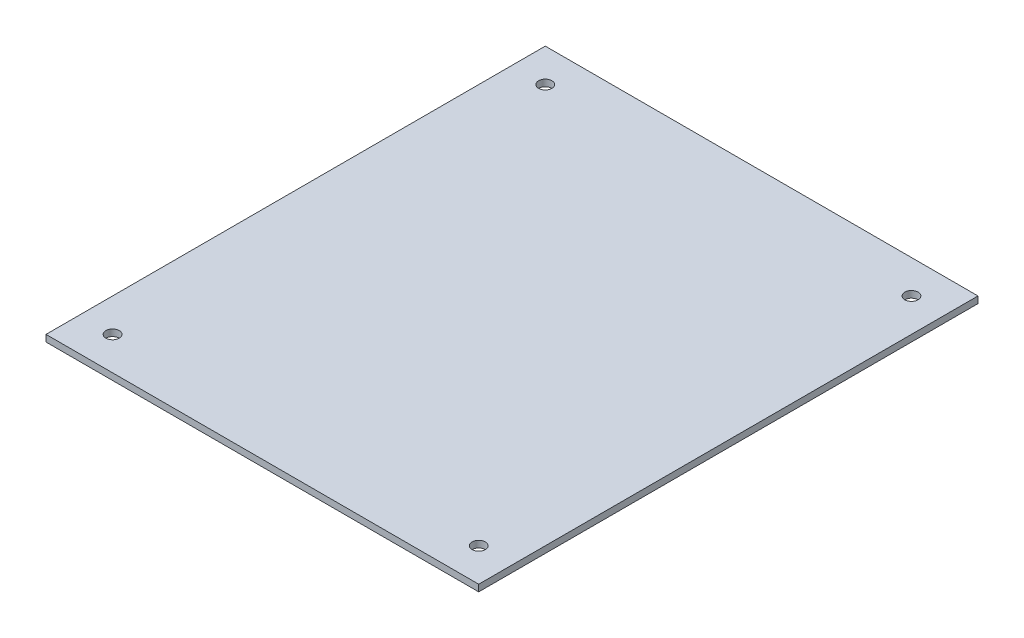
from build123d import *

# Parameters (mm, degrees)
SKETCH1_W           = 130
SKETCH1_H           = 150
BOSS_EXTRUDE1_DEPTH = 2
SKETCH2_R           = 2
CUT_EXTRUDE1_DEPTH  = 3


with BuildPart() as part:
    # Sketch1 → Boss-Extrude1 (new body)
    with BuildSketch(Plane(origin=(0, 0, 0), x_dir=(1, 0, 0), z_dir=(0, 1, 0))):
        Rectangle(SKETCH1_W, SKETCH1_H)
    extrude(amount=BOSS_EXTRUDE1_DEPTH)

    # Sketch2 → Cut-Extrude1 (cut, through all)
    with BuildSketch(Plane(origin=(0, 2, 0), x_dir=(1, 0, 0), z_dir=(0, 1, 0))):
        with Locations((-55, 65)):
            Circle(SKETCH2_R)
        with Locations((55, 65)):
            Circle(SKETCH2_R)
        with Locations((55, -65)):
            Circle(SKETCH2_R)
        with Locations((-55, -65)):
            Circle(SKETCH2_R)
    extrude(amount=-CUT_EXTRUDE1_DEPTH, mode=Mode.SUBTRACT)


solid = part.part
